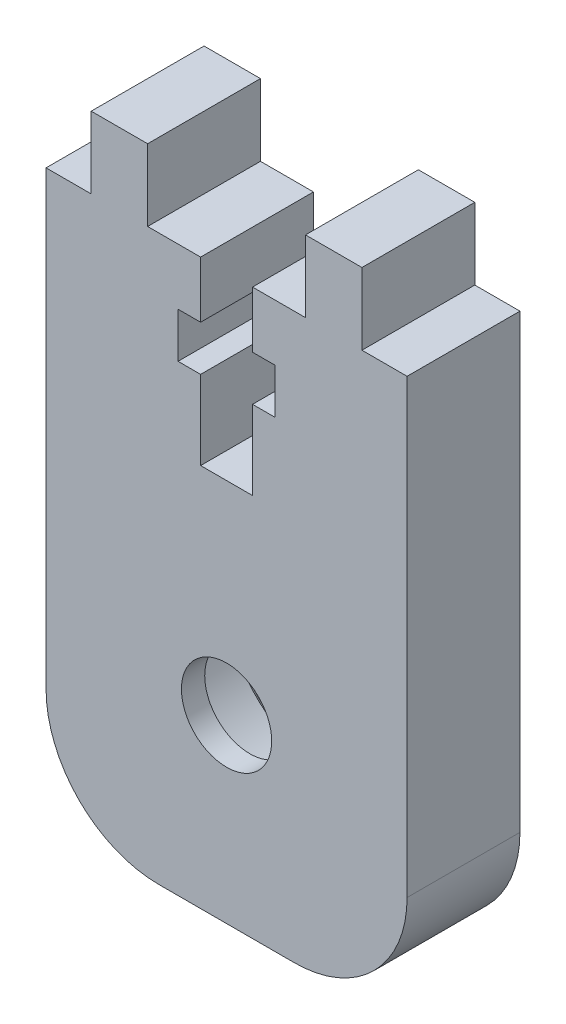
from build123d import *

# Parameters (mm, degrees)
BOSS_EXTRUDE1_DEPTH = 5
SKETCH2_R           = 4.9
CUT_EXTRUDE1_DEPTH  = 3.96875
CUT_EXTRUDE2_REACH  = 3.031
SKETCH3_R           = 2
FILLET1_R           = 5
CHAMFER1_SIZE       = 0.2
SKETCH5_R           = 0.15


with BuildPart() as part:
    # Sketch1 → Boss-Extrude1 (new body)
    with BuildSketch(Plane.XY):
        Polygon((7.998, 12.5), (5.998, 12.5), (5.998, 15.675), (3.498, 15.675), (3.498, 12.5), (1.15, 12.5), (1.15, 10), (2.15, 10), (2.15, 8), (1.15, 8), (1.15, 4.5), (-1.15, 4.5), (-1.15, 8), (-2.15, 8), (-2.15, 10), (-1.15, 10), (-1.15, 12.5), (-3.498, 12.5), (-3.498, 15.675), (-5.998, 15.675), (-5.998, 12.5), (-7.998, 12.5), (-7.998, -12.5), (7.998, -12.5), align=None)
    extrude(amount=BOSS_EXTRUDE1_DEPTH)

    # Sketch2 → Cut-Extrude1 (cut)
    with BuildSketch(Plane(origin=(0, 0, 0), x_dir=(-1, 0, 0), z_dir=(0, 0, -1))):
        with Locations((0, -4.5)):
            Circle(SKETCH2_R)
    extrude(amount=-CUT_EXTRUDE1_DEPTH, mode=Mode.SUBTRACT)

    # Sketch3 → Cut-Extrude2 (cut, up to next)
    with BuildSketch(Plane(origin=(0, 0, 3.96875), x_dir=(-1, 0, 0), z_dir=(0, 0, -1)), mode=Mode.PRIVATE) as cut_extrude2_sk1:
        with Locations((0, -4.5)):
            Circle(SKETCH3_R)
    cut_extrude2_tool1 = extrude(cut_extrude2_sk1.sketch, amount=-CUT_EXTRUDE2_REACH, mode=Mode.PRIVATE) & part.part
    add(cut_extrude2_tool1.solids().sort_by_distance((0, -4.5, 3.96875))[0], mode=Mode.SUBTRACT)

    # Fillet1
    fillet1_edges = [part.edges().sort_by_distance(p)[0] for p in [
        (7.998, -12.5, 2.5),
        (-7.998, -12.5, 2.5),
    ]]
    fillet(fillet1_edges, radius=FILLET1_R)

    # Chamfer1
    chamfer1_edges = [part.edges().sort_by_distance(p)[0] for p in [
        (4.9, -4.5, 0),
    ]]
    chamfer(chamfer1_edges, length=CHAMFER1_SIZE)

    # Sketch5 → Cut-Revolve1 (revolve, cut)
    with BuildSketch(Plane(origin=(0, 0, 0), x_dir=(0, 0, -1), z_dir=(1, 0, 0))):
        with Locations((-3.86875, -9.3)):
            Circle(SKETCH5_R)
    revolve(axis=Axis((0, -4.5, 5), (0, 0, -1)), mode=Mode.SUBTRACT)


solid = part.part
